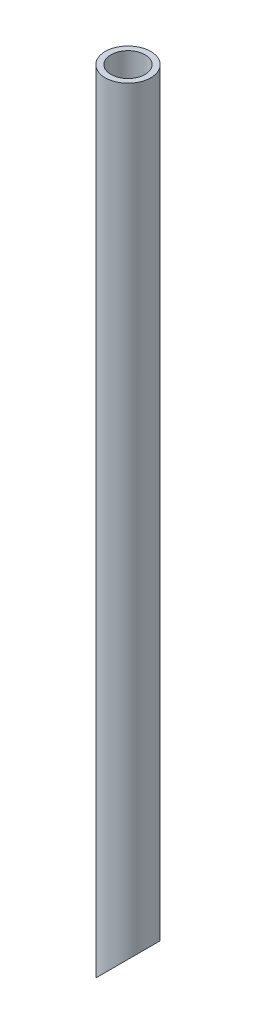
from build123d import *

# Parameters (mm, degrees)
SKETCH_1_R               = 2
SKETCH_1_R_2             = 1.5
EXTRUDE_1_DEPTH          = 70
CUT_EXTRUDE_1_DEPTH      = 3
CUT_EXTRUDE_1_DEPTH_BACK = 3


with BuildPart() as part:
    # Эскиз1 → Бобышка-Вытянуть1 (new body)
    with BuildSketch(Plane(origin=(0, 0, 0), x_dir=(1, 0, 0), z_dir=(0, 1, 0))):
        Circle(SKETCH_1_R)
        Circle(SKETCH_1_R_2, mode=Mode.SUBTRACT)
    extrude(amount=EXTRUDE_1_DEPTH)

    # Эскиз2 → Вырез-Вытянуть1 (cut, two sides)
    with BuildSketch(Plane.XY) as cut_extrude_1_sk:
        Polygon((-2, 0), (2.956455922, 4.956455922), (2.956455922, -0.426685723), (-2, -0.426685723), align=None)
    extrude(amount=CUT_EXTRUDE_1_DEPTH, mode=Mode.SUBTRACT)
    extrude(cut_extrude_1_sk.sketch, amount=-CUT_EXTRUDE_1_DEPTH_BACK, mode=Mode.SUBTRACT)


solid = part.part
